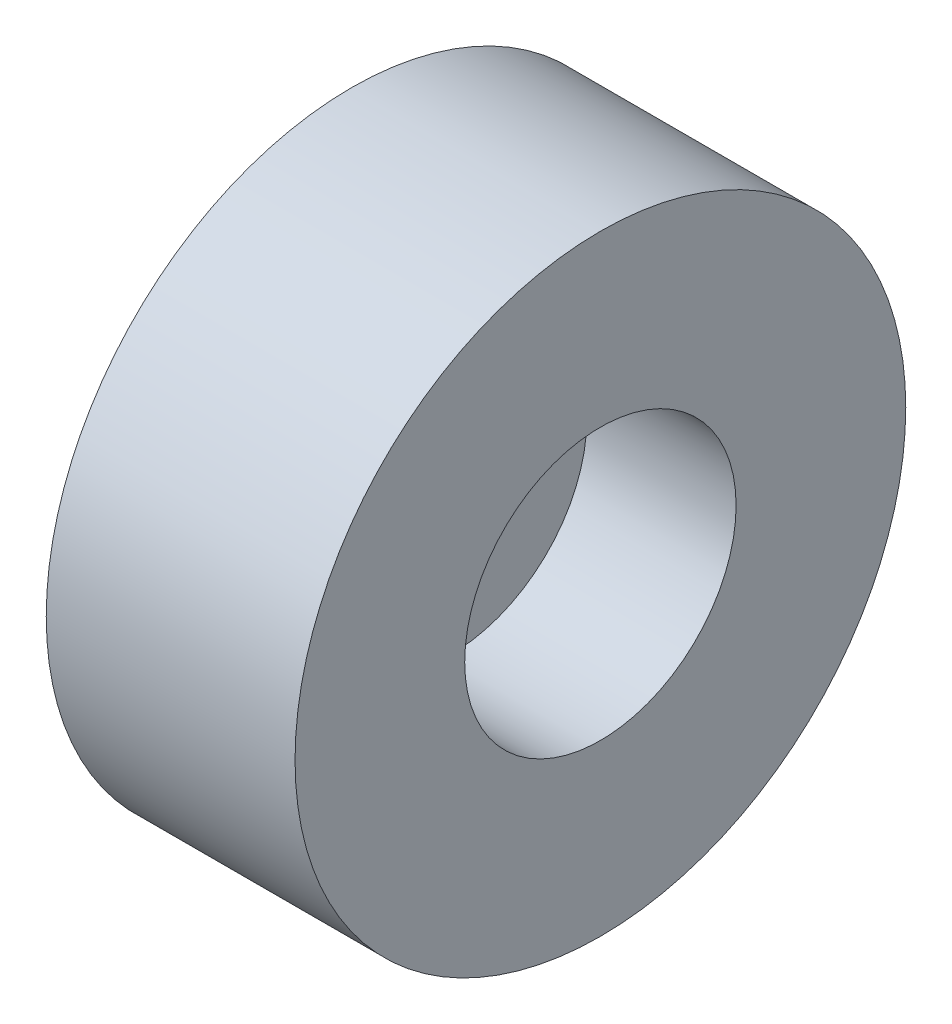
from build123d import *

# Parameters (mm, degrees)
SKETCH1_R           = 6.75
BOSS_EXTRUDE1_DEPTH = 5.5
SKETCH2_R           = 3
CUT_EXTRUDE1_DEPTH  = 3.3
SKETCH3_R           = 1.5
CUT_EXTRUDE2_DEPTH  = 3.3


with BuildPart() as part:
    # Sketch1 → Boss-Extrude1 (new body)
    with BuildSketch(Plane(origin=(0, 0, 0), x_dir=(0, 0, -1), z_dir=(1, 0, 0))):
        Circle(SKETCH1_R)
    extrude(amount=BOSS_EXTRUDE1_DEPTH)

    # Sketch2 → Cut-Extrude1 (cut)
    with BuildSketch(Plane(origin=(5.5, 0, 0), x_dir=(0, 0, -1), z_dir=(1, 0, 0))):
        Circle(SKETCH2_R)
    extrude(amount=-CUT_EXTRUDE1_DEPTH, mode=Mode.SUBTRACT)

    # Sketch3 → Cut-Extrude2 (cut)
    with BuildSketch(Plane(origin=(2.2, 0, 0), x_dir=(0, 0, -1), z_dir=(1, 0, 0))):
        Circle(SKETCH3_R)
    extrude(amount=-CUT_EXTRUDE2_DEPTH, mode=Mode.SUBTRACT)


solid = part.part
